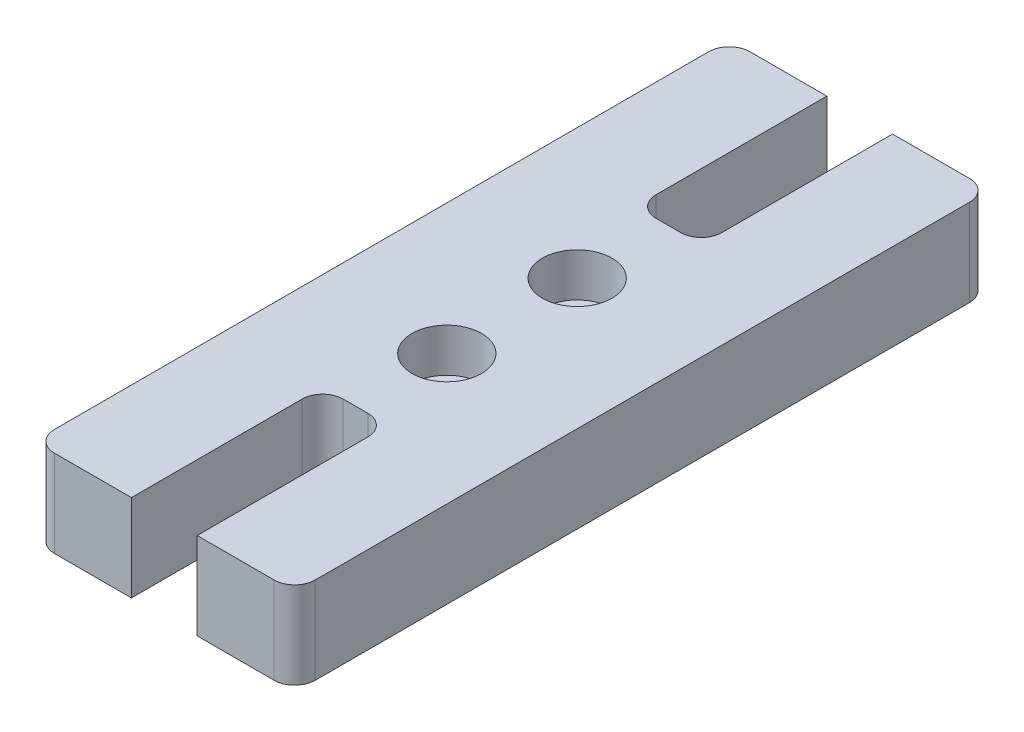
from build123d import *

# Parameters (mm, degrees)
SKETCH1_W           = 19.05
SKETCH1_H           = 50.8
BOSS_EXTRUDE1_DEPTH = 6.35
CUT_EXTRUDE1_START  = -7.35
SKETCH2_R           = 1.7272
CUT_EXTRUDE1_DEPTH  = 8.35
SKETCH3_R           = 2.54
CUT_EXTRUDE2_DEPTH  = 3.175
SKETCH4_W           = 4.8006
SKETCH4_H           = 13.97
CUT_EXTRUDE3_DEPTH  = 7.35
FILLET2_R           = 1.5


with BuildPart() as part:
    # Sketch1 → Boss-Extrude1 (new body)
    with BuildSketch(Plane(origin=(0, 0, 0), x_dir=(1, 0, 0), z_dir=(0, 1, 0))):
        Rectangle(SKETCH1_W, SKETCH1_H)
    extrude(amount=BOSS_EXTRUDE1_DEPTH)

    # Sketch2 → Cut-Extrude1 (cut)
    with BuildSketch(Plane(origin=(0, 6.35, 0), x_dir=(1, 0, 0), z_dir=(0, 1, 0)).offset(CUT_EXTRUDE1_START)):
        with Locations((0, 4.7625)):
            Circle(SKETCH2_R)
    cut_extrude1 = extrude(amount=CUT_EXTRUDE1_DEPTH, mode=Mode.SUBTRACT)

    # Sketch3 → Cut-Extrude2 (cut)
    with BuildSketch(Plane(origin=(0, 6.35, 0), x_dir=(1, 0, 0), z_dir=(0, 1, 0))):
        with Locations((0, 4.7625)):
            Circle(SKETCH3_R)
    cut_extrude2 = extrude(amount=-CUT_EXTRUDE2_DEPTH, mode=Mode.SUBTRACT)

    # Sketch4 → Cut-Extrude3 (cut, through all)
    with BuildSketch(Plane(origin=(0, 6.35, 0), x_dir=(1, 0, 0), z_dir=(0, 1, 0))):
        with Locations((0, 18.415)):
            Rectangle(SKETCH4_W, SKETCH4_H)
    cut_extrude3 = extrude(amount=-CUT_EXTRUDE3_DEPTH, mode=Mode.SUBTRACT)

    # Mirror1: Cut-Extrude1, Cut-Extrude2, Cut-Extrude3 across plane
    add(cut_extrude1.mirror(Plane.XY), mode=Mode.SUBTRACT)
    add(cut_extrude2.mirror(Plane.XY), mode=Mode.SUBTRACT)
    add(cut_extrude3.mirror(Plane.XY), mode=Mode.SUBTRACT)

    # Fillet2
    fillet2_edges = [part.edges().sort_by_distance(p)[0] for p in [
        (2.4003, 3.175, -11.43),
        (-2.4003, 3.175, -11.43),
        (2.4003, 3.175, 11.43),
        (-2.4003, 3.175, 11.43),
        (9.525, 3.175, 25.4),
        (-9.525, 3.175, 25.4),
        (-9.525, 3.175, -25.4),
        (9.525, 3.175, -25.4),
    ]]
    fillet(fillet2_edges, radius=FILLET2_R)


solid = part.part
